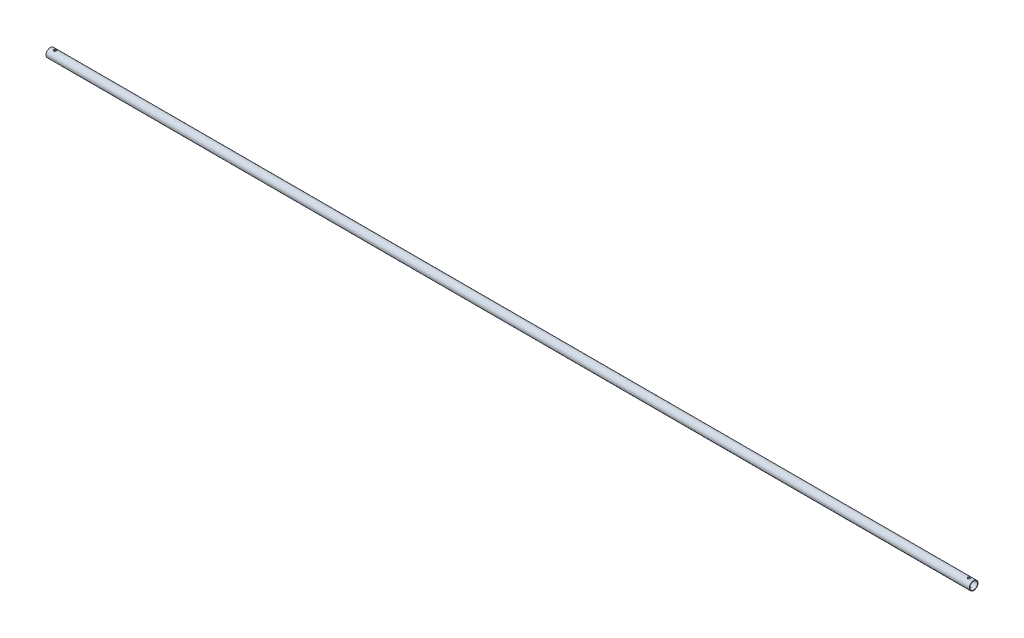
from build123d import *

# Parameters (mm, degrees)
SKETCH1_R           = 11.7094
SKETCH1_R_2         = 10.4648
BOSS_EXTRUDE1_DEPTH = 2501.9
SKETCH2_R           = 3.3782
CUT_EXTRUDE1_DEPTH  = 12.7094


with BuildPart() as part:
    # Sketch1 → Boss-Extrude1 (new body)
    with BuildSketch(Plane(origin=(0, 0, 0), x_dir=(0, 0, -1), z_dir=(1, 0, 0))):
        Circle(SKETCH1_R)
        Circle(SKETCH1_R_2, mode=Mode.SUBTRACT)
    extrude(amount=BOSS_EXTRUDE1_DEPTH)

    # Sketch2 → Cut-Extrude1 (cut, symmetric)
    with BuildSketch(Plane(origin=(0, 0, 0), x_dir=(1, 0, 0), z_dir=(0, 1, 0))):
        with Locations((12.7, 0)):
            Circle(SKETCH2_R)
    cut_extrude1 = extrude(amount=CUT_EXTRUDE1_DEPTH, both=True, mode=Mode.SUBTRACT)

    # Mirror1: Cut-Extrude1 across plane
    add(cut_extrude1.mirror(Plane.ZY.offset(-1250.95)), mode=Mode.SUBTRACT)


solid = part.part
